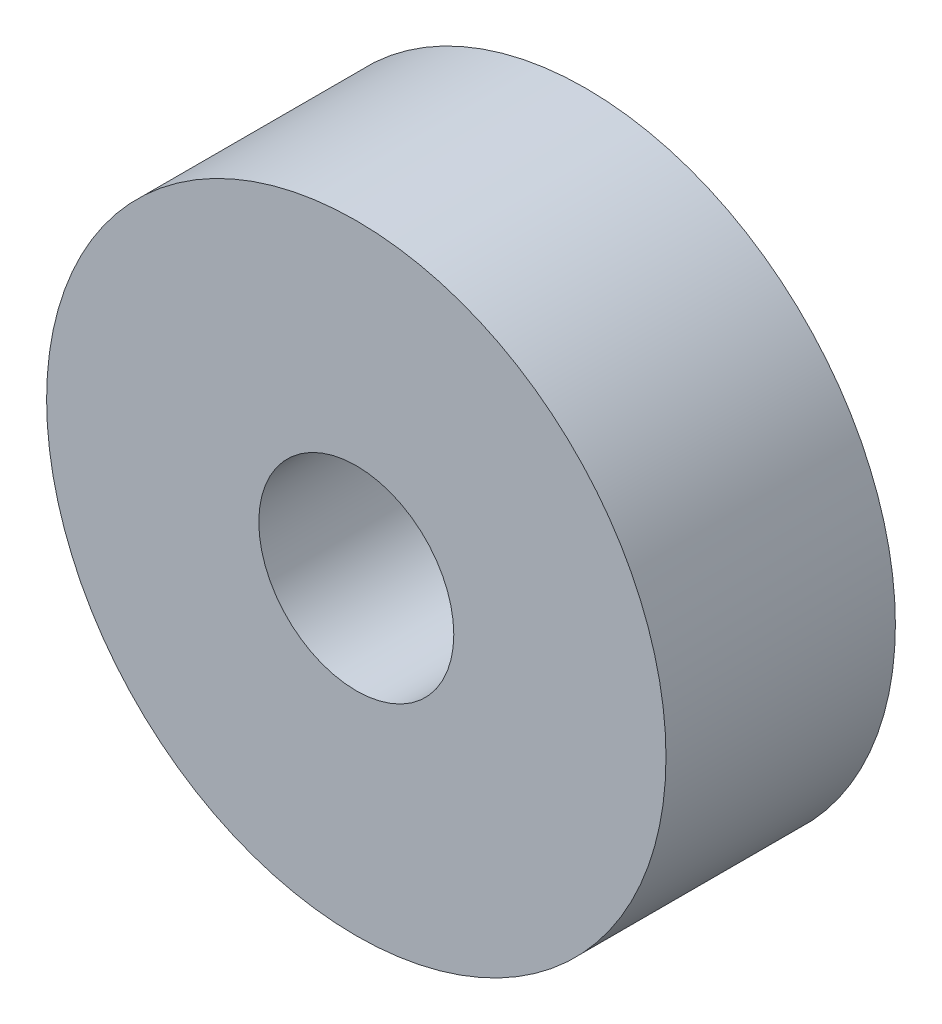
from build123d import *

# Parameters (mm, degrees)
SKETCH1_R           = 27
BOSS_EXTRUDE1_DEPTH = 20
CUT_EXTRUDE1_REACH  = 22
SKETCH2_R           = 8.5


with BuildPart() as part:
    # Sketch1 → Boss-Extrude1 (new body)
    with BuildSketch(Plane.XY):
        Circle(SKETCH1_R)
    extrude(amount=BOSS_EXTRUDE1_DEPTH)

    # Sketch2 → Cut-Extrude1 (cut, up to next)
    with BuildSketch(Plane.XY.offset(20), mode=Mode.PRIVATE) as cut_extrude1_sk1:
        Circle(SKETCH2_R)
    cut_extrude1_tool1 = extrude(cut_extrude1_sk1.sketch, amount=-CUT_EXTRUDE1_REACH, mode=Mode.PRIVATE) & part.part
    add(cut_extrude1_tool1.solids().sort_by_distance((0, 0, 20))[0], mode=Mode.SUBTRACT)


solid = part.part
